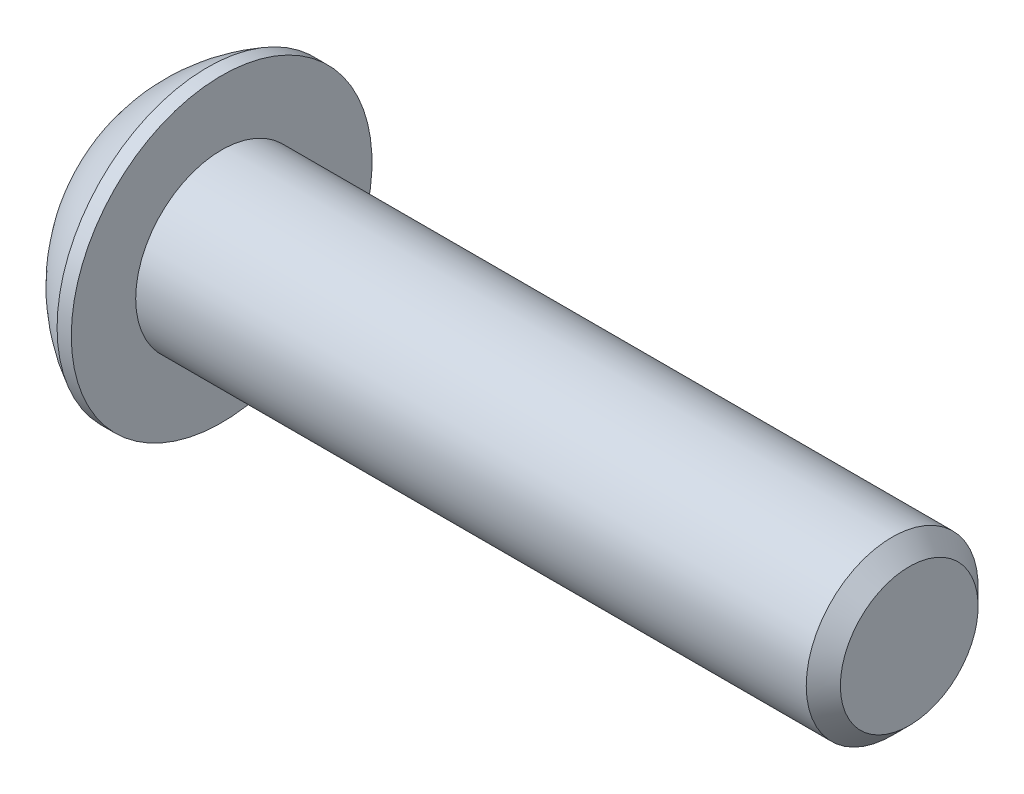
from build123d import *

# Parameters (mm, degrees)
HEX_2_DEPTH = 3.0988


with BuildPart() as part:
    # BodySke → BaseBody (revolve)
    with BuildSketch(Plane.XY, mode=Mode.PRIVATE) as basebody_sk:
        with BuildLine():
            Line((42.9768, 0), (42.9768, 3.81635))
            Line((42.9768, 3.81635), (42.03065, 4.7625))
            Line((42.03065, 4.7625), (4.8768, 4.7625))
            Line((4.8768, 4.7625), (4.8768, 8.3312))
            Line((4.8768, 8.3312), (4.0894, 8.3312))
            ThreePointArc((4.0894, 8.3312), (1.712581673, 6.574442992), (0, 4.1656))
            Line((0, 4.1656), (0, 0))
            Line((0, 0), (42.9768, 0))
        make_face()
    revolve(basebody_sk.sketch.rotate(Axis((0, 0, 0), (1, 0, 0)), 90), axis=Axis((0, 0, 0), (1, 0, 0)))  # turned: the seam where the file's is

    # Sketch2 → PreBroach (revolve, cut)
    with BuildSketch(Plane.XY, mode=Mode.PRIVATE) as prebroach_sk:
        Polygon((0, 2.7813), (3.0988, 2.7813), (4.704584304, 0), (0, 0), align=None)
    revolve(prebroach_sk.sketch.rotate(Axis((0, 0, 0), (1, 0, 0)), 90), axis=Axis((0, 0, 0), (1, 0, 0)), mode=Mode.SUBTRACT)  # turned: the seam where the file's is

    # Sketch3 → Hex 2 (cut)
    with BuildSketch(Plane(origin=(0, 0, 0), x_dir=(0, 0, -1), z_dir=(1, 0, 0))):
        Polygon((-2.7813, -1.605784304), (-2.7813, 1.605784304), (0, 3.211568607), (2.7813, 1.605784304), (2.7813, -1.605784304), (0, -3.211568607), align=None)
    extrude(amount=HEX_2_DEPTH, mode=Mode.SUBTRACT)


solid = part.part
